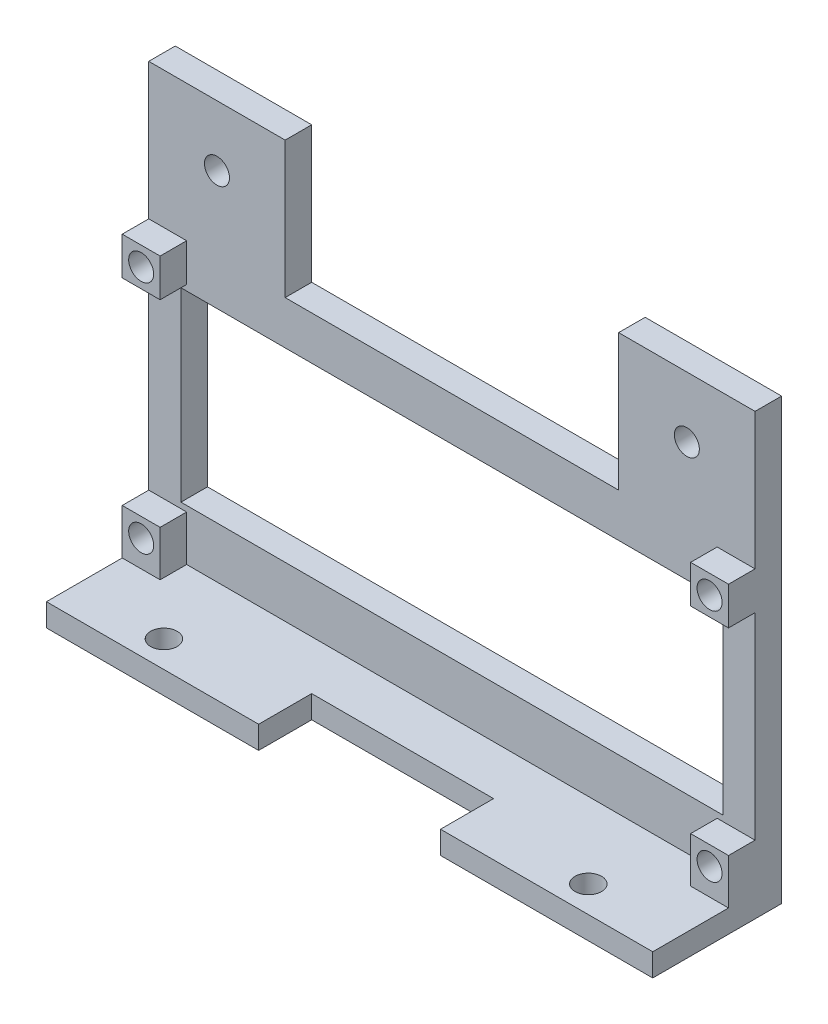
from build123d import *

# Parameters (mm, degrees)
SKETCH1_W           = 80
SKETCH1_H           = 36
SKETCH1_R           = 1.65
SKETCH1_W_2         = 71.5
SKETCH1_H_2         = 24.5
BOSS_EXTRUDE1_DEPTH = 3.5
SKETCH2_W           = 5
SKETCH2_H           = 5
SKETCH2_R           = 1.65
BOSS_EXTRUDE2_DEPTH = 3.5
BOSS_EXTRUDE4_DEPTH = 1
BOSS_EXTRUDE5_START = 1
SKETCH3_R           = 1.75
BOSS_EXTRUDE5_DEPTH = 3
SKETCH7_W           = 18
SKETCH7_H           = 18
SKETCH7_R           = 1.65
BOSS_EXTRUDE6_DEPTH = 3.5


with BuildPart() as part:
    # Sketch1 → Boss-Extrude1 (new body)
    with BuildSketch(Plane.XY):
        with Locations((35.75, 12.25)):
            Rectangle(SKETCH1_W, SKETCH1_H)
        with Locations((-1.75, 27.75)):
            Circle(SKETCH1_R, mode=Mode.SUBTRACT)
        with Locations((73.25, 27.75)):
            Circle(SKETCH1_R, mode=Mode.SUBTRACT)
        with Locations((73.25, -3.25)):
            Circle(SKETCH1_R, mode=Mode.SUBTRACT)
        with Locations((-1.75, -3.25)):
            Circle(SKETCH1_R, mode=Mode.SUBTRACT)
        with Locations((35.75, 12.25)):
            Rectangle(SKETCH1_W_2, SKETCH1_H_2, mode=Mode.SUBTRACT)
    extrude(amount=BOSS_EXTRUDE1_DEPTH)

    # Sketch2 → Boss-Extrude2 (add)
    with BuildSketch(Plane.XY.offset(3.5)):
        with Locations((-1.75, 27.75)):
            Rectangle(SKETCH2_W, SKETCH2_H)
        with Locations((-1.75, 27.75)):
            Circle(SKETCH2_R, mode=Mode.SUBTRACT)
        with Locations((73.25, 27.75)):
            Rectangle(SKETCH2_W, SKETCH2_H)
        with Locations((73.25, 27.75)):
            Circle(SKETCH2_R, mode=Mode.SUBTRACT)
        with Locations((-1.75, -3.25)):
            Rectangle(SKETCH2_W, SKETCH2_H)
        with Locations((-1.75, -3.25)):
            Circle(SKETCH2_R, mode=Mode.SUBTRACT)
        with Locations((73.25, -3.25)):
            Rectangle(SKETCH2_W, SKETCH2_H)
        with Locations((73.25, -3.25)):
            Circle(SKETCH2_R, mode=Mode.SUBTRACT)
    extrude(amount=BOSS_EXTRUDE2_DEPTH)

    # Sketch6 → Boss-Extrude4 (add)
    with BuildSketch(Plane.XZ.offset(5.75)):
        Polygon((-4.25, 0), (-4.25, 7), (0.75, 7), (0.75, 3.5), (70.75, 3.5), (70.75, 7), (75.75, 7), (75.75, 0), align=None)
    extrude(amount=BOSS_EXTRUDE4_DEPTH)

    # Sketch3 → Boss-Extrude5 (add)
    with BuildSketch(Plane(origin=(0, -5.75, 0), x_dir=(-1, 0, 0), z_dir=(0, -1, 0)).offset(BOSS_EXTRUDE5_START)):
        Polygon((-47.75, -17), (-47.75, -10), (-23.75, -10), (-23.75, -17), (4.25, -17), (4.25, 0), (-75.75, 0), (-75.75, -17), align=None)
        with Locations((-7.75, -13.5)):
            Circle(SKETCH3_R, mode=Mode.SUBTRACT)
        with Locations((-63.75, -13.5)):
            Circle(SKETCH3_R, mode=Mode.SUBTRACT)
    extrude(amount=BOSS_EXTRUDE5_DEPTH)

    # Sketch7 → Boss-Extrude6 (add)
    with BuildSketch(Plane(origin=(0, 0, 0), x_dir=(-1, 0, 0), z_dir=(0, 0, -1))):
        with Locations((-66.75, 39.25)):
            Rectangle(SKETCH7_W, SKETCH7_H)
        with Locations((-66.75, 40.25)):
            Circle(SKETCH7_R, mode=Mode.SUBTRACT)
        with Locations((-4.75, 39.25)):
            Rectangle(SKETCH7_W, SKETCH7_H)
        with Locations((-4.75, 40.25)):
            Circle(SKETCH7_R, mode=Mode.SUBTRACT)
    extrude(amount=-BOSS_EXTRUDE6_DEPTH)


solid = part.part
